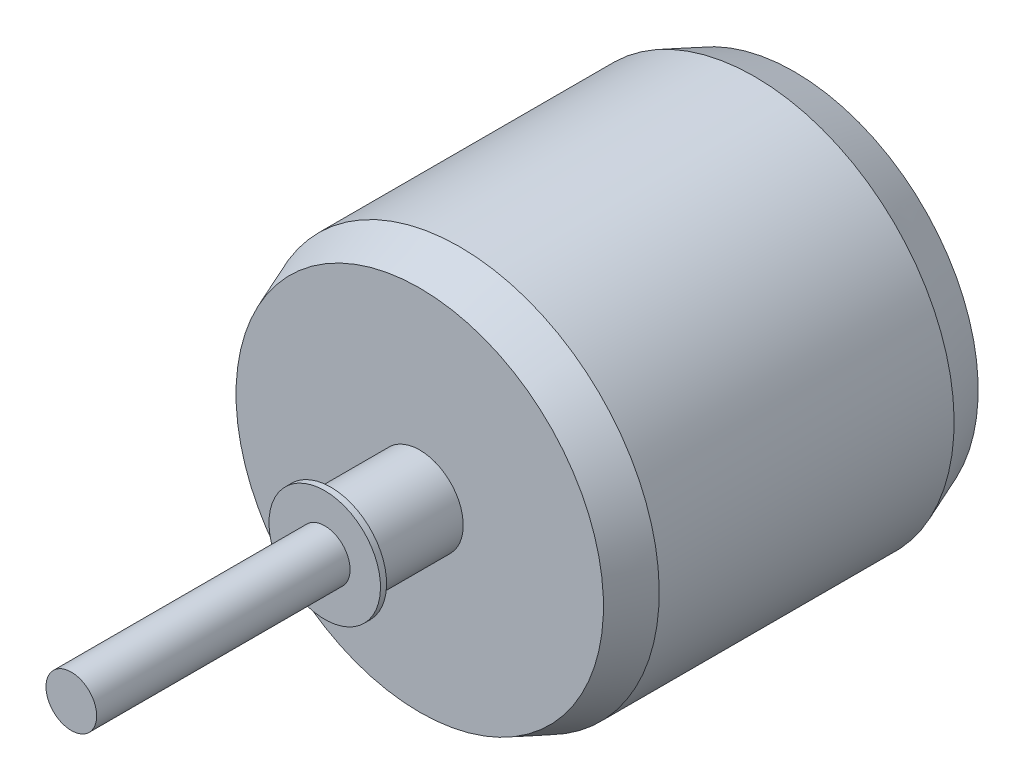
from build123d import *


with BuildPart() as part:
    # Sketch1 → Revolve2 (revolve)
    with BuildSketch(Plane(origin=(0, 0, 0), x_dir=(0, 0, -1), z_dir=(1, 0, 0))):
        Polygon((58.65, 0), (-58.65, 0), (-58.65, 4), (-18.65, 4), (-18.65, 8.8), (-17.684615329, 8.8), (-16.745087162, 6.860466242), (-3.65, 6.860466242), (-3.65, 29), (2.650046163, 31.5), (49.2, 31.5), (55.5, 29), (55.5, 7), (58.65, 7), align=None)
    revolve(axis=Axis((0, 0, -93.114456369), (0, 0, 1)))


solid = part.part
